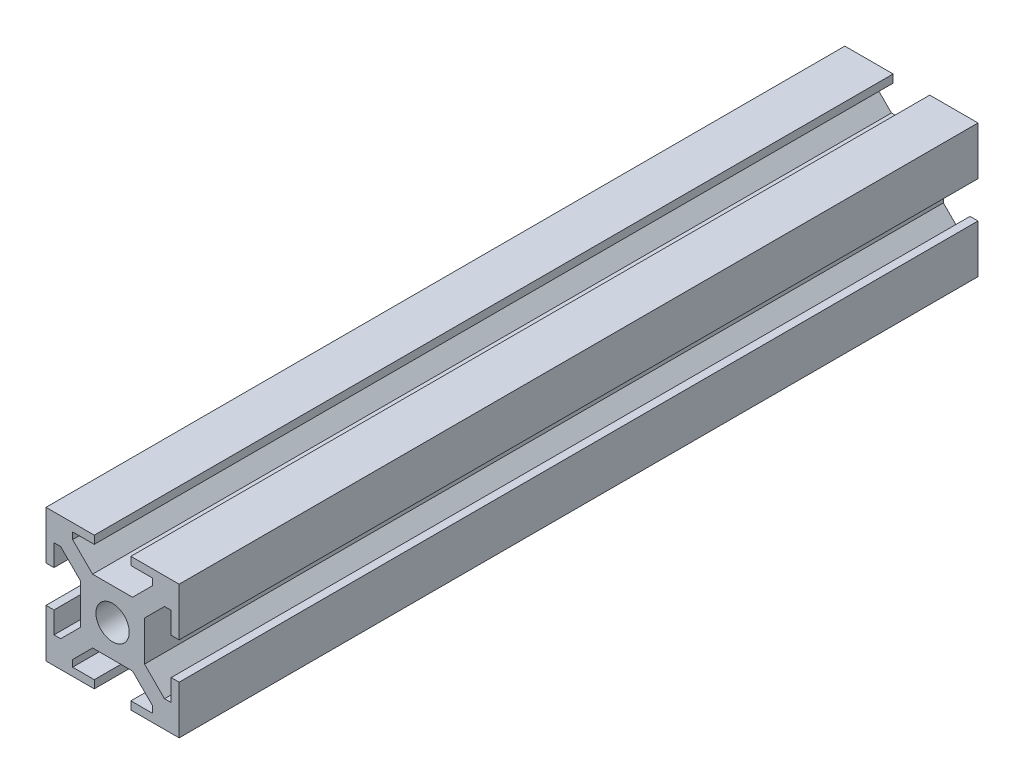
from build123d import *

# Parameters (mm, degrees)
ESQUISSE1_W             = 20
ESQUISSE1_H             = 20
BOSS_EXTRU_1_DEPTH      = 120
ESQUISSE2_W             = 1.2
ESQUISSE2_H             = 5.5
ESQUISSE2_W_2           = 5.5
ESQUISSE2_H_2           = 1.2
ENL_V_MAT_EXTRU_1_DEPTH = 121
ENL_V_MAT_EXTRU_2_DEPTH = 121
ESQUISSE4_R             = 2.5
ENL_V_MAT_EXTRU_3_DEPTH = 121


with BuildPart() as part:
    # Esquisse1 → Boss.-Extru.1 (new body)
    with BuildSketch(Plane.XY):
        with Locations((-12.505109137, -9.909560068)):
            Rectangle(ESQUISSE1_W, ESQUISSE1_H)
    extrude(amount=BOSS_EXTRU_1_DEPTH)

    # Esquisse2 → Enlèv. mat.-Extru.1 (cut, through all)
    with BuildSketch(Plane.XY.offset(120)):
        with Locations((-21.905109137, -9.909560068)):
            Rectangle(ESQUISSE2_W, ESQUISSE2_H)
        with Locations((-12.505109137, -0.509560068)):
            Rectangle(ESQUISSE2_W_2, ESQUISSE2_H_2)
        with Locations((-3.105109137, -9.909560068)):
            Rectangle(ESQUISSE2_W, ESQUISSE2_H)
        with Locations((-12.505109137, -19.309560068)):
            Rectangle(ESQUISSE2_W_2, ESQUISSE2_H_2)
    extrude(amount=-ENL_V_MAT_EXTRU_1_DEPTH, mode=Mode.SUBTRACT)

    # Esquisse3 → Enlèv. mat.-Extru.2 (cut, through all)
    with BuildSketch(Plane.XY.offset(120)):
        Polygon((-21.305109137, -15.909560068), (-20.305109137, -15.909560068), (-17.305109137, -12.909560068), (-17.305109137, -6.909560068), (-20.305109137, -3.909560068), (-21.305109137, -3.909560068), align=None)
        Polygon((-18.505109137, -1.109560068), (-6.505109137, -1.109560068), (-6.505109137, -2.109560068), (-9.505109137, -5.109560068), (-15.505109137, -5.109560068), (-18.505109137, -2.109560068), align=None)
        Polygon((-3.705109137, -3.909560068), (-4.705109137, -3.909560068), (-7.705109137, -6.909560068), (-7.705109137, -12.909560068), (-4.705109137, -15.909560068), (-3.705109137, -15.909560068), align=None)
        Polygon((-6.505109137, -18.709560068), (-18.505109137, -18.709560068), (-18.505109137, -17.709560068), (-15.505109137, -14.709560068), (-9.505109137, -14.709560068), (-6.505109137, -17.709560068), align=None)
    extrude(amount=-ENL_V_MAT_EXTRU_2_DEPTH, mode=Mode.SUBTRACT)

    # Esquisse4 → Enlèv. mat.-Extru.3 (cut, through all)
    with BuildSketch(Plane.XY.offset(120)):
        with Locations((-12.505109137, -9.909560068)):
            Circle(ESQUISSE4_R)
    extrude(amount=-ENL_V_MAT_EXTRU_3_DEPTH, mode=Mode.SUBTRACT)


solid = part.part
